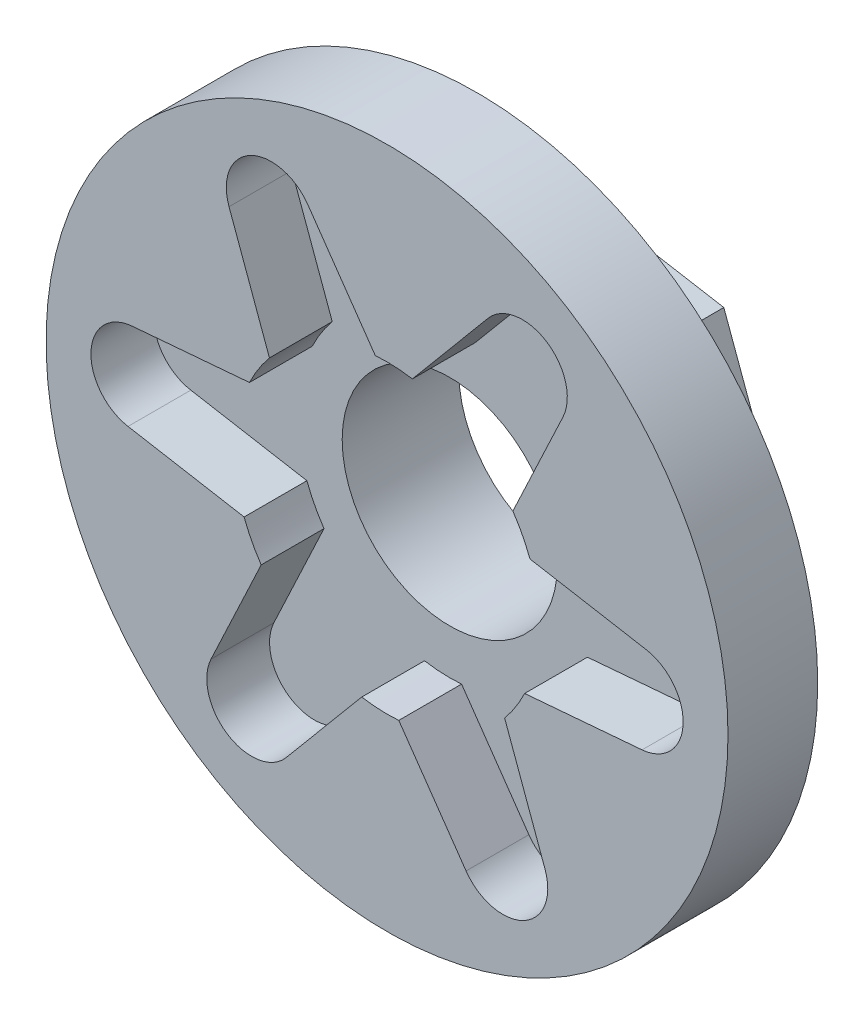
from build123d import *

# Parameters (mm, degrees)
BOSS_EXTRUDE1_DEPTH = 5
SKETCH2_R           = 19
BOSS_EXTRUDE2_DEPTH = 5
CUT_EXTRUDE1_DEPTH  = 3.5
SKETCH4_R           = 6
CUT_EXTRUDE2_DEPTH  = 11


with BuildPart() as part:
    # Sketch1 → Boss-Extrude1 (new body)
    with BuildSketch(Plane.XY):
        Polygon((8.766334056, 10.506254671), (-4.715516416, 12.844995326), (-13.481850472, 2.338740655), (-8.766334056, -10.506254671), (4.715516416, -12.844995326), (13.481850472, -2.338740655), align=None)
    extrude(amount=BOSS_EXTRUDE1_DEPTH)

    # Sketch2 → Boss-Extrude2 (add)
    with BuildSketch(Plane.XY.offset(5)):
        Circle(SKETCH2_R)
    extrude(amount=BOSS_EXTRUDE2_DEPTH)

    # Sketch3 → Cut-Extrude1 (cut)
    with BuildSketch(Plane.XY.offset(10)):
        with BuildLine():
            Line((7.666666546, -3.670452843), (14.211444215, -3.120072648))
            ThreePointArc((14.211444215, -3.120072648), (16.499429689, -0.741033748), (14.433922262, 1.833530816))
            Line((14.433922262, 1.833530816), (7.964835621, 2.968399152))
            ThreePointArc((7.964835621, 2.968399152), (7.544489735, 3.915440541), (7.012038678, 4.80430157))
            Line((7.012038678, 4.80430157), (9.807784283, 10.74743539))
            ThreePointArc((9.807784283, 10.74743539), (8.89146974, 13.918407845), (5.629078153, 13.4169103))
            Line((5.629078153, 13.4169103), (1.411708737, 8.381949561))
            ThreePointArc((1.411708737, 8.381949561), (0.381373892, 8.49144004), (-0.654627868, 8.474754413))
            Line((-0.654627868, 8.474754413), (-4.403659932, 13.867508039))
            ThreePointArc((-4.403659932, 13.867508039), (-7.607959927, 14.659442582), (-8.804846066, 11.583379783))
            Line((-8.804846066, 11.583379783), (-6.553126885, 5.413550409))
            ThreePointArc((-6.553126885, 5.413550409), (-7.163115843, 4.575999499), (-7.666666546, 3.670452843))
            Line((-7.666666546, 3.670452843), (-14.211444215, 3.120072648))
            ThreePointArc((-14.211444215, 3.120072648), (-16.499429618, 0.741035318), (-14.433925359, -1.833530273))
            Line((-14.433925359, -1.833530273), (-7.964835621, -2.968399152))
            ThreePointArc((-7.964835621, -2.968399152), (-7.544489735, -3.915440541), (-7.012038678, -4.80430157))
            Line((-7.012038678, -4.80430157), (-9.807784283, -10.74743539))
            ThreePointArc((-9.807784283, -10.74743539), (-8.891470467, -13.918407381), (-5.629079261, -13.416911623))
            Line((-5.629079261, -13.416911623), (-1.411708737, -8.381949561))
            ThreePointArc((-1.411708737, -8.381949561), (-0.381373892, -8.49144004), (0.654627868, -8.474754413))
            Line((0.654627868, -8.474754413), (4.403659932, -13.867508039))
            ThreePointArc((4.403659932, -13.867508039), (7.607959014, -14.659443056), (8.804846772, -11.583381715))
            Line((8.804846772, -11.583381715), (6.553126885, -5.413550409))
            ThreePointArc((6.553126885, -5.413550409), (7.163115843, -4.575999499), (7.666666546, -3.670452843))
        make_face()
    extrude(amount=-CUT_EXTRUDE1_DEPTH, mode=Mode.SUBTRACT)

    # Sketch4 → Cut-Extrude2 (cut, through all)
    with BuildSketch(Plane(origin=(0, 0, 0), x_dir=(-1, 0, 0), z_dir=(0, 0, -1))):
        Circle(SKETCH4_R)
    extrude(amount=-CUT_EXTRUDE2_DEPTH, mode=Mode.SUBTRACT)


solid = part.part
